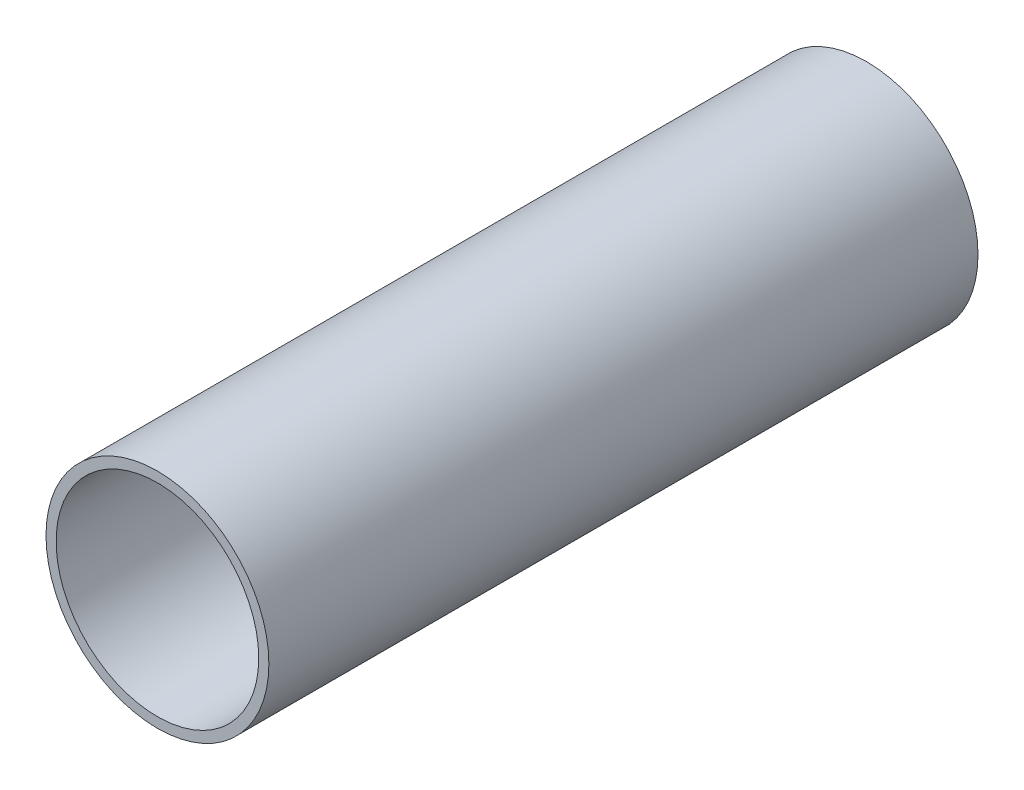
from build123d import *

# Parameters (mm, degrees)
SKETCH_1_R      = 11
SKETCH_1_R_2    = 10
EXTRUDE_1_DEPTH = 70


with BuildPart() as part:
    # Эскиз1 → Бобышка-Вытянуть1 (new body)
    with BuildSketch(Plane.XY):
        Circle(SKETCH_1_R)
        Circle(SKETCH_1_R_2, mode=Mode.SUBTRACT)
    extrude(amount=EXTRUDE_1_DEPTH)


solid = part.part
